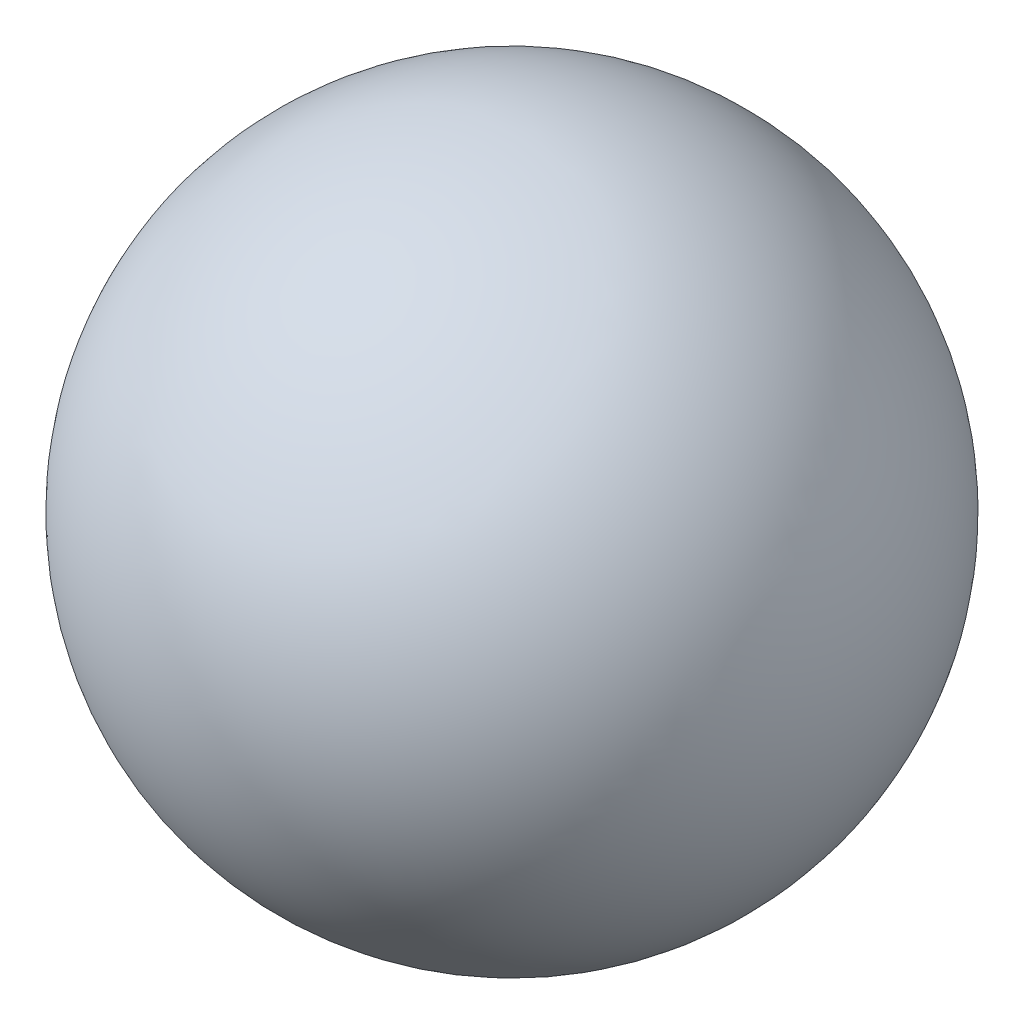
from build123d import *


with BuildPart() as part:
    # Sketch1 → Revolve1 (revolve)
    with BuildSketch(Plane.XY):
        with BuildLine():
            Line((0.75, 0), (-0.75, 0))
            ThreePointArc((-0.75, 0), (0, -0.75), (0.75, 0))
        make_face()
    revolve(axis=Axis((-13.28796663, 0, 0), (1, 0, 0)))


solid = part.part
